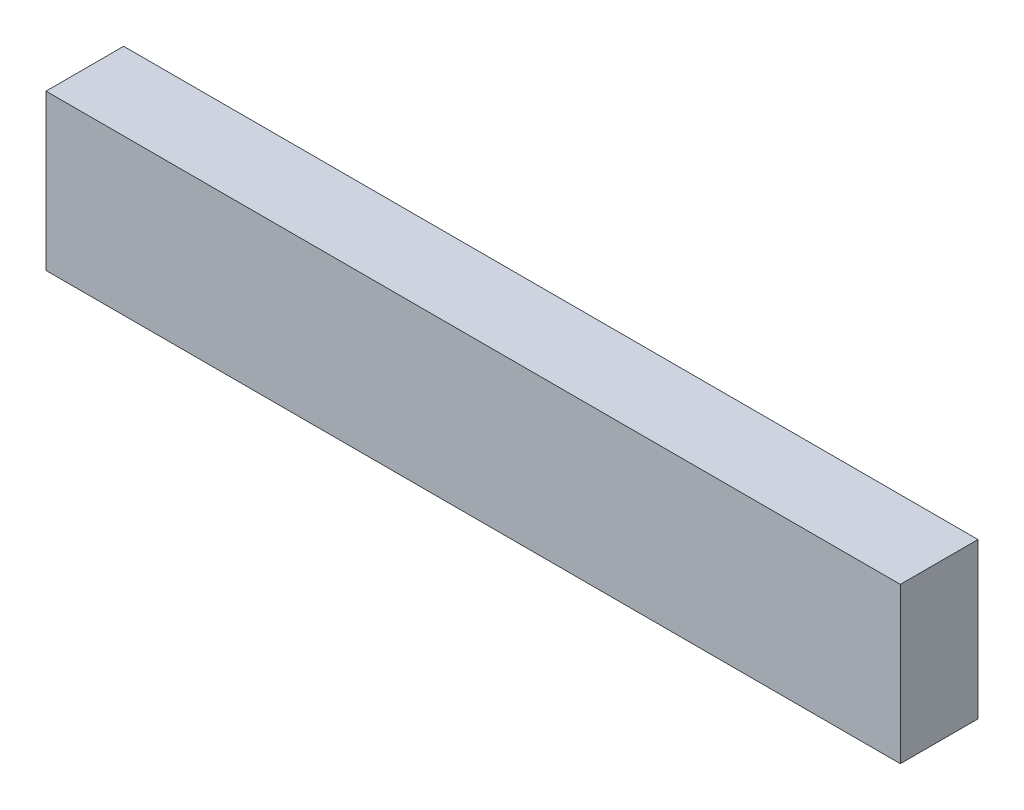
from build123d import *

# Parameters (mm, degrees)
SKETCH_1_W      = 20
SKETCH_1_H      = 40
EXTRUDE_1_DEPTH = 220


with BuildPart() as part:
    # Эскиз1 → Бобышка-Вытянуть1 (new body)
    with BuildSketch(Plane(origin=(0, 0, 0), x_dir=(0, 0, -1), z_dir=(1, 0, 0))):
        with Locations((10, 20)):
            Rectangle(SKETCH_1_W, SKETCH_1_H)
    extrude(amount=EXTRUDE_1_DEPTH)


solid = part.part
